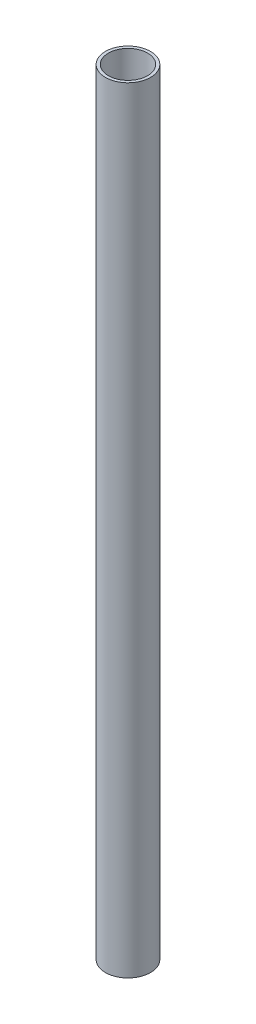
from build123d import *

# Parameters (mm, degrees)
SKETCH1_R           = 5.9055
SKETCH1_R_2         = 5.1435
BOSS_EXTRUDE1_DEPTH = 203.2


with BuildPart() as part:
    # Sketch1 → Boss-Extrude1 (new body)
    with BuildSketch(Plane(origin=(0, 0, 0), x_dir=(1, 0, 0), z_dir=(0, 1, 0))):
        Circle(SKETCH1_R)
        Circle(SKETCH1_R_2, mode=Mode.SUBTRACT)
    extrude(amount=BOSS_EXTRUDE1_DEPTH)


solid = part.part
